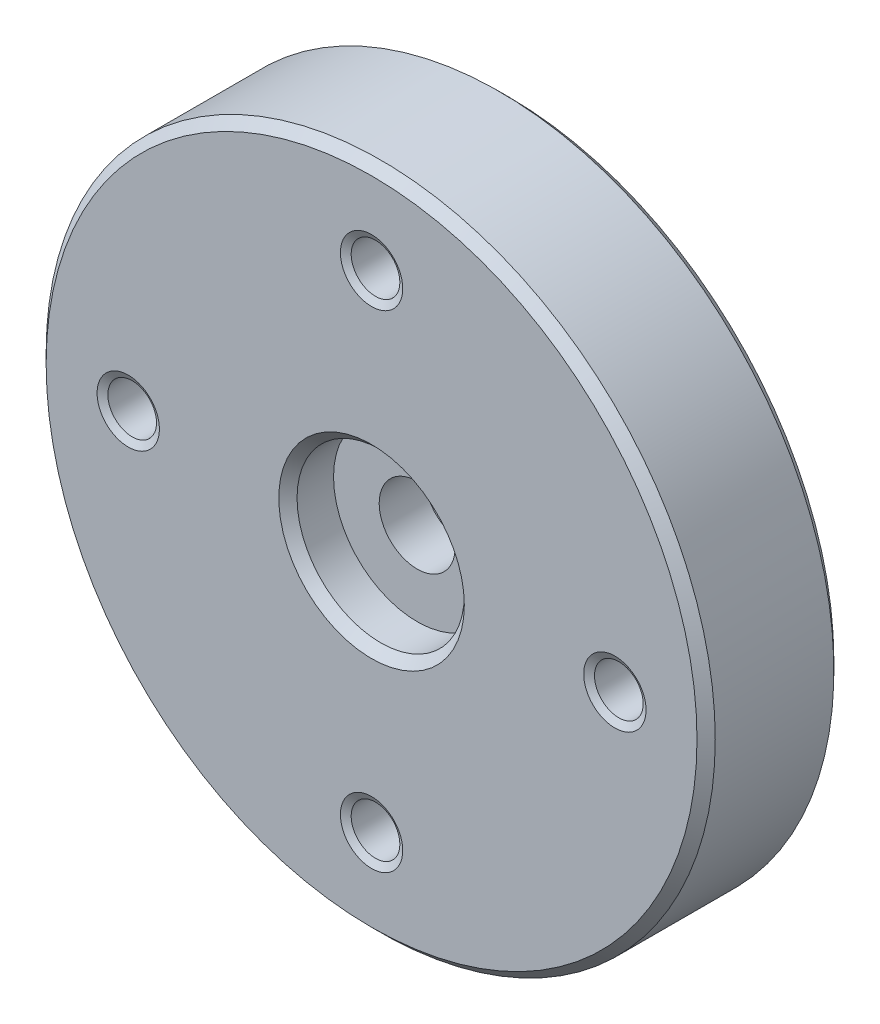
from build123d import *

# Parameters (mm, degrees)
M2_TAPPED_HOLE1_AT_2_COUNT = 2
M2_TAPPED_HOLE1_AT_2_PITCH = 11.313708499
M2_TAPPED_HOLE1_AT_3_COUNT = 2
M2_TAPPED_HOLE1_AT_3_PITCH = 16
M2_TAPPED_HOLE1_AT_4_COUNT = 2
M2_TAPPED_HOLE1_AT_4_PITCH = 11.313708499
M2_TAPPED_HOLE1_AT_5_COUNT = 2
M2_TAPPED_HOLE1_AT_5_PITCH = 8
CHAMFER1_SIZE              = 0.3


with BuildPart() as part:
    # Sketch1 → Revolve1 (revolve)
    with BuildSketch(Plane(origin=(0, 0, 0), x_dir=(0, 0, -1), z_dir=(1, 0, 0))):
        Polygon((3, 1.25), (1.5, 1.25), (1.5, 2.75), (0, 2.75), (0, 11), (4.5, 11), (4.5, 4.5), (6.7, 4.5), (6.7, 2.75), (3, 2.75), align=None)
    revolve(axis=Axis((0, 0, 0), (0, 0, 1)))

    # Sketch4 → M2 Tapped Hole1 (revolve, cut)
    with BuildSketch(Plane(origin=(0, 8, 0), x_dir=(0, -1, 0), z_dir=(1, 0, 0))):
        Polygon((0, 0), (0, 4.5), (1.025, 4.5), (0.8, 4.370096189), (0.8, 0.129903811), (1.025, 0), align=None)
    m2_tapped_hole1 = revolve(axis=Axis((0, 8, 6.35), (0, 0, -1)), mode=Mode.SUBTRACT)

    # M2 Tapped Hole1 at 2: M2 Tapped Hole1 ×2
    with Locations(*[Vector(0.707106781, -0.707106781, 0) * (i * M2_TAPPED_HOLE1_AT_2_PITCH) for i in range(1, M2_TAPPED_HOLE1_AT_2_COUNT)]):
        add(m2_tapped_hole1, mode=Mode.SUBTRACT)

    # M2 Tapped Hole1 at 3: M2 Tapped Hole1 ×2
    with Locations(*[(0, -i * M2_TAPPED_HOLE1_AT_3_PITCH, 0) for i in range(1, M2_TAPPED_HOLE1_AT_3_COUNT)]):
        add(m2_tapped_hole1, mode=Mode.SUBTRACT)

    # M2 Tapped Hole1 at 4: M2 Tapped Hole1 ×2
    with Locations(*[Vector(-0.707106781, -0.707106781, 0) * (i * M2_TAPPED_HOLE1_AT_4_PITCH) for i in range(1, M2_TAPPED_HOLE1_AT_4_COUNT)]):
        add(m2_tapped_hole1, mode=Mode.SUBTRACT)

    # M2 Tapped Hole1 at 5: M2 Tapped Hole1 ×2
    with Locations(*[(0, -i * M2_TAPPED_HOLE1_AT_5_PITCH, 0) for i in range(1, M2_TAPPED_HOLE1_AT_5_COUNT)]):
        add(m2_tapped_hole1, mode=Mode.SUBTRACT)

    # Chamfer1
    chamfer1_edges = [part.edges().sort_by_distance(p)[0] for p in [
        (0, -11, -4.5),
        (0, -11, 0),
        (0, -2.75, 0),
        (0, -4.5, -6.7),
    ]]
    chamfer(chamfer1_edges, length=CHAMFER1_SIZE)


solid = part.part
